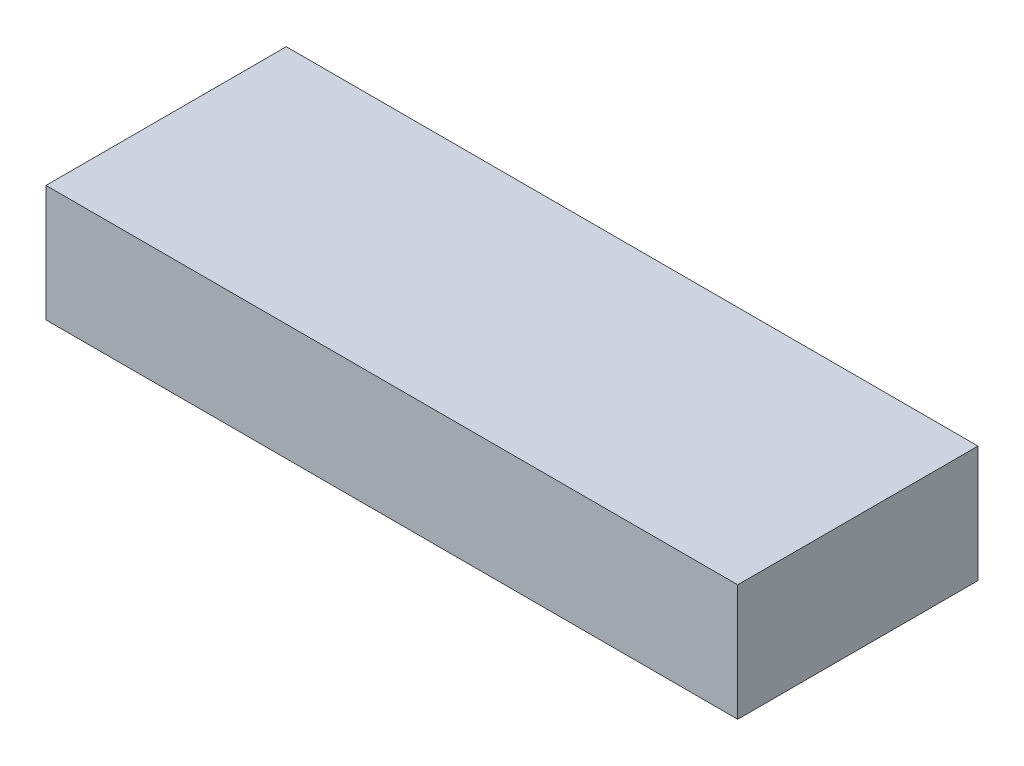
from build123d import *

# Parameters (mm, degrees)
SKETCH1_W           = 47.5
SKETCH1_H           = 16.5
BOSS_EXTRUDE1_DEPTH = 8


with BuildPart() as part:
    # Sketch1 → Boss-Extrude1 (new body)
    with BuildSketch(Plane(origin=(0, 0, 0), x_dir=(1, 0, 0), z_dir=(0, 1, 0))):
        Rectangle(SKETCH1_W, SKETCH1_H)
    extrude(amount=BOSS_EXTRUDE1_DEPTH)


solid = part.part
